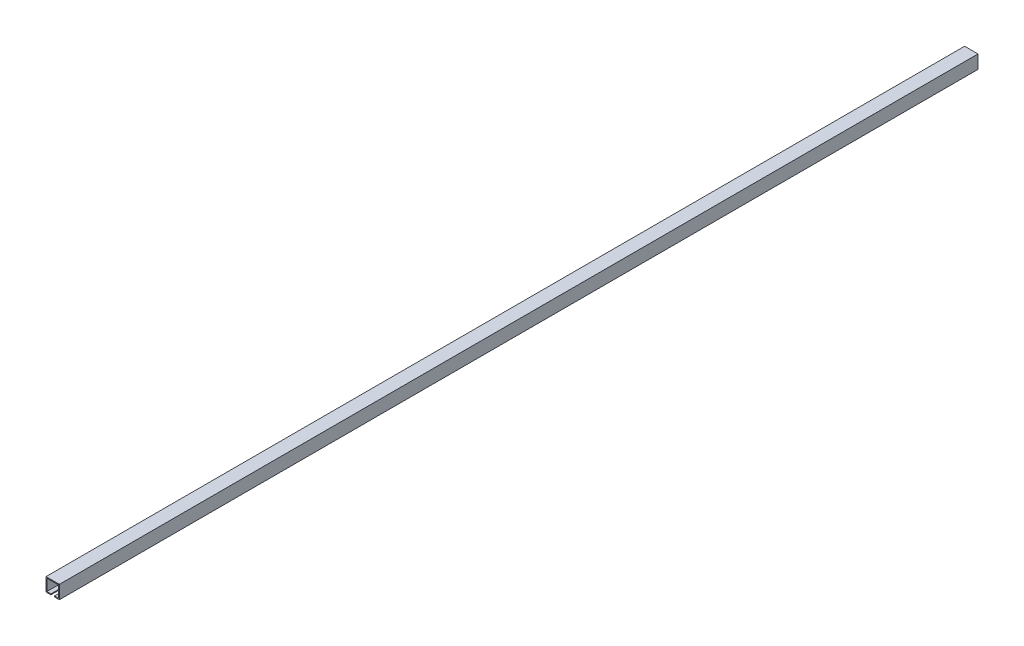
from build123d import *

# Parameters (mm, degrees)
BOSS_EXTRUDE1_DEPTH = 1030


with BuildPart() as part:
    # Sketch1 → Boss-Extrude1 (new body, symmetric)
    with BuildSketch(Plane.XY):
        Polygon((-4, -13), (-4, -15), (-15, -15), (-15, 15), (15, 15), (15, -15), (4, -15), (4, -13), (13, -13), (13, 13), (-13, 13), (-13, -13), align=None)
    extrude(amount=BOSS_EXTRUDE1_DEPTH, both=True)


solid = part.part
